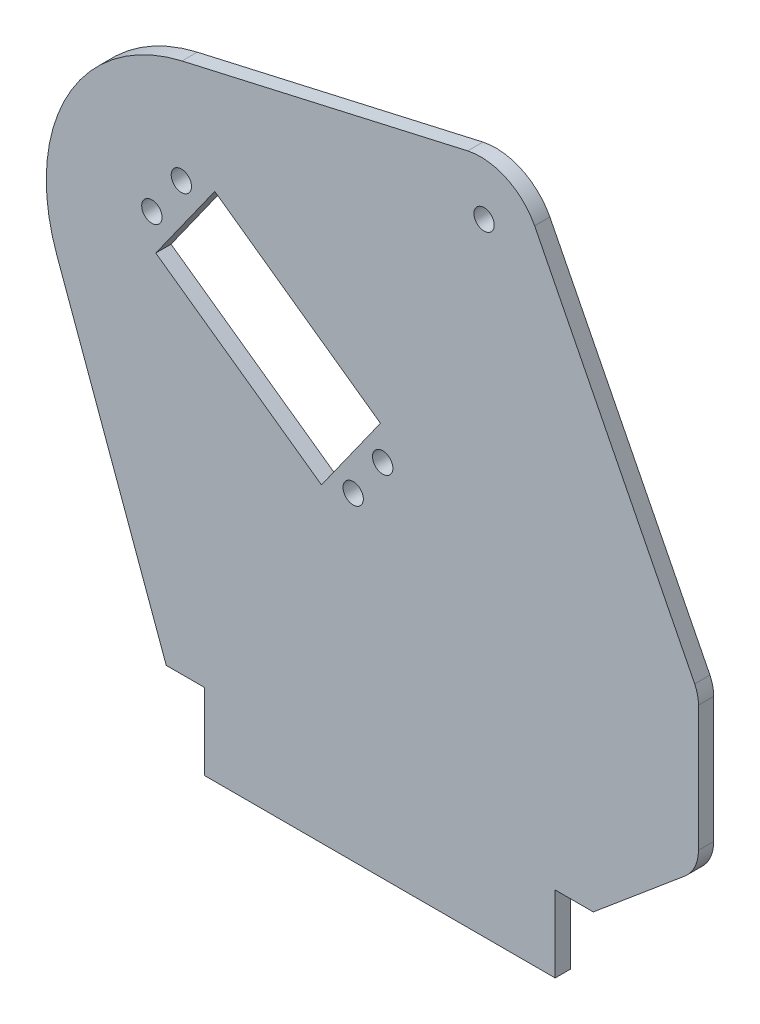
from build123d import *

# Parameters (mm, degrees)
SKETCH_1_R      = 2
EXTRUDE_1_DEPTH = 3


with BuildPart() as part:
    # 草圖1 → 填料-伸長1 (new body)
    with BuildSketch(Plane.XY):
        with BuildLine():
            Line((59.29779344, 4.218826045), (27.815049638, 66.504924261))
            ThreePointArc((27.815049638, 66.504924261), (22.280452319, 71.817413106), (14.658767156, 72.691610154))
            Line((14.658767156, 72.691610154), (-41.535085268, 59.909886888))
            ThreePointArc((-41.535085268, 59.909886888), (-64.065081782, 42.747842637), (-66.156088343, 14.503122823))
            Line((-66.156088343, 14.503122823), (-44.645241189, -44.597442609))
            Line((-44.645241189, -44.597442609), (-37.145243156, -44.597442609))
            Line((-37.145243156, -44.597442609), (-37.145243156, -59.597442609))
            Line((-37.145243156, -59.597442609), (31.854756844, -59.597442609))
            Line((31.854756844, -59.597442609), (31.854756844, -44.597442609))
            Line((31.854756844, -44.597442609), (39.352422835, -44.597442609))
            Line((39.352422835, -44.597442609), (57.472801714, -29.392639375))
            ThreePointArc((57.472801714, -29.392639375), (59.36662348, -26.84637358), (60.037958839, -23.74486762))
            Line((60.037958839, -23.74486762), (60.037958839, 0.970036375))
            ThreePointArc((60.037958839, 0.970036375), (59.850576653, 2.636055511), (59.29779344, 4.218826045))
        make_face()
        with Locations((17.869885774, 62.635186946)):
            Circle(SKETCH_1_R, mode=Mode.SUBTRACT)
        with Locations((-2.073498249, 11.257790191)):
            Circle(SKETCH_1_R, mode=Mode.SUBTRACT)
        with Locations((-7.872108914, 3.110636432)):
            Circle(SKETCH_1_R, mode=Mode.SUBTRACT)
        with Locations((-41.668665513, 39.439038022)):
            Circle(SKETCH_1_R, mode=Mode.SUBTRACT)
        with Locations((-47.467276178, 31.291884264)):
            Circle(SKETCH_1_R, mode=Mode.SUBTRACT)
        Polygon((-40.901751655, 32.756086344), (-46.700362319, 24.608932586), (-14.111747287, 1.414489926), (-2.514525958, 17.708797442), (-35.10314099, 40.903240102), align=None, mode=Mode.SUBTRACT)
    extrude(amount=EXTRUDE_1_DEPTH)


solid = part.part
